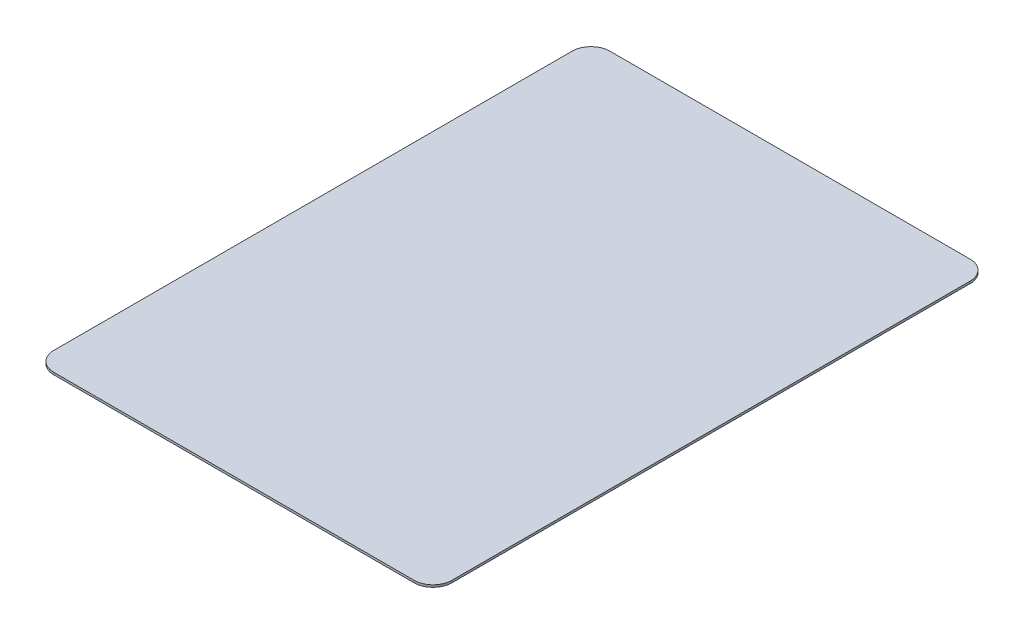
from build123d import *

# Parameters (mm, degrees)
BOSS_EXTRUDE1_DEPTH = 0.35


with BuildPart() as part:
    # Sketch1 → Boss-Extrude1 (new body)
    with BuildSketch(Plane(origin=(0, 0, 0), x_dir=(1, 0, 0), z_dir=(0, 1, 0))):
        with BuildLine():
            Line((28.5, -44), (-28.5, -44))
            ThreePointArc((-28.5, -44), (-30.621320344, -43.121320344), (-31.5, -41))
            Line((-31.5, -41), (-31.5, 41))
            ThreePointArc((-31.5, 41), (-30.621320344, 43.121320344), (-28.5, 44))
            Line((-28.5, 44), (28.5, 44))
            ThreePointArc((28.5, 44), (30.621320344, 43.121320344), (31.5, 41))
            Line((31.5, 41), (31.5, -41))
            ThreePointArc((31.5, -41), (30.621320344, -43.121320344), (28.5, -44))
        make_face()
    extrude(amount=BOSS_EXTRUDE1_DEPTH)


solid = part.part
